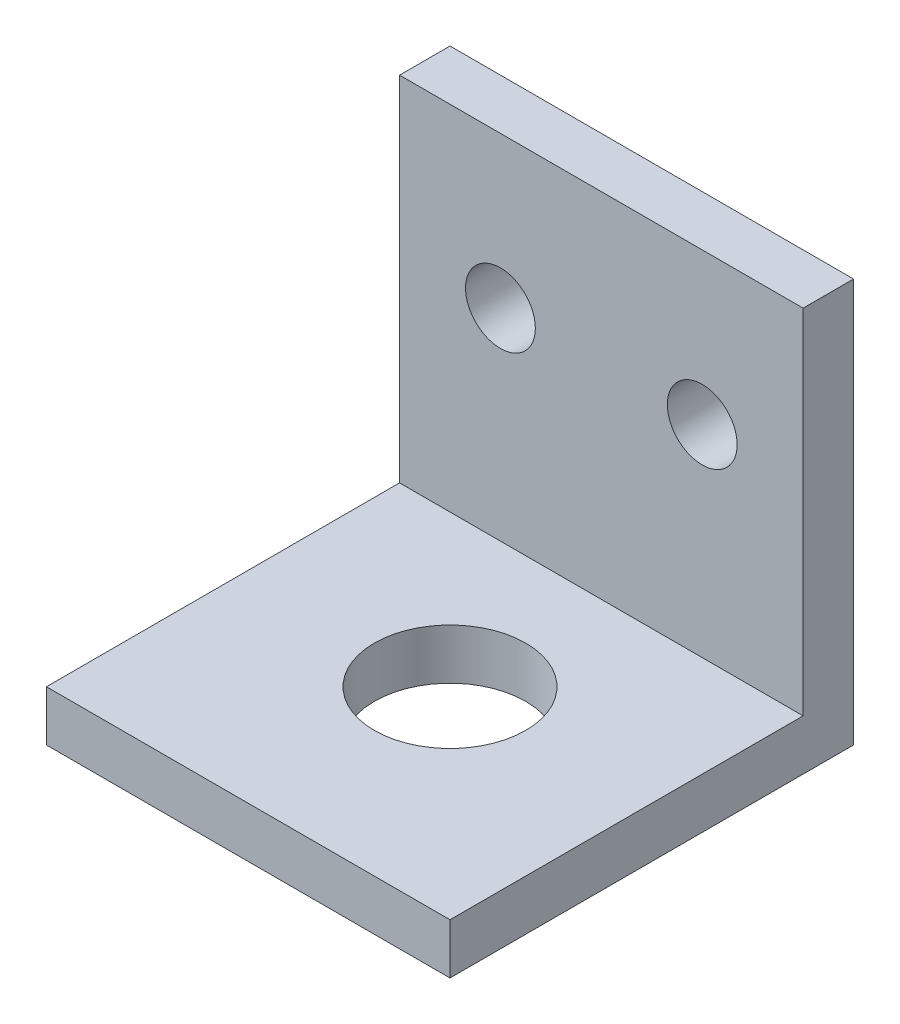
from build123d import *

# Parameters (mm, degrees)
SKETCH1_W           = 25.4
SKETCH1_H           = 25.4
BOSS_EXTRUDE1_DEPTH = 3.175
SKETCH2_W           = 25.4
SKETCH2_H           = 3.175
BOSS_EXTRUDE2_DEPTH = 25.4
SKETCH3_R           = 4.7625
CUT_EXTRUDE1_DEPTH  = 4.175
SKETCH4_R           = 2.1971
CUT_EXTRUDE2_DEPTH  = 4.175


with BuildPart() as part:
    # Sketch1 → Boss-Extrude1 (new body)
    with BuildSketch(Plane(origin=(0, 0, 0), x_dir=(1, 0, 0), z_dir=(0, 1, 0))):
        Rectangle(SKETCH1_W, SKETCH1_H)
    extrude(amount=BOSS_EXTRUDE1_DEPTH)

    # Sketch2 → Boss-Extrude2 (add)
    with BuildSketch(Plane.XZ):
        with Locations((0, -11.1125)):
            Rectangle(SKETCH2_W, SKETCH2_H)
    extrude(amount=-BOSS_EXTRUDE2_DEPTH)

    # Sketch3 → Cut-Extrude1 (cut, through all)
    with BuildSketch(Plane(origin=(0, 3.175, 0), x_dir=(1, 0, 0), z_dir=(0, 1, 0))):
        Circle(SKETCH3_R)
    extrude(amount=-CUT_EXTRUDE1_DEPTH, mode=Mode.SUBTRACT)

    # Sketch4 → Cut-Extrude2 (cut, through all)
    with BuildSketch(Plane.XY.offset(-9.525)):
        with Locations((-6.35, 15.875)):
            Circle(SKETCH4_R)
        with Locations((6.35, 15.875)):
            Circle(SKETCH4_R)
    extrude(amount=-CUT_EXTRUDE2_DEPTH, mode=Mode.SUBTRACT)


solid = part.part
